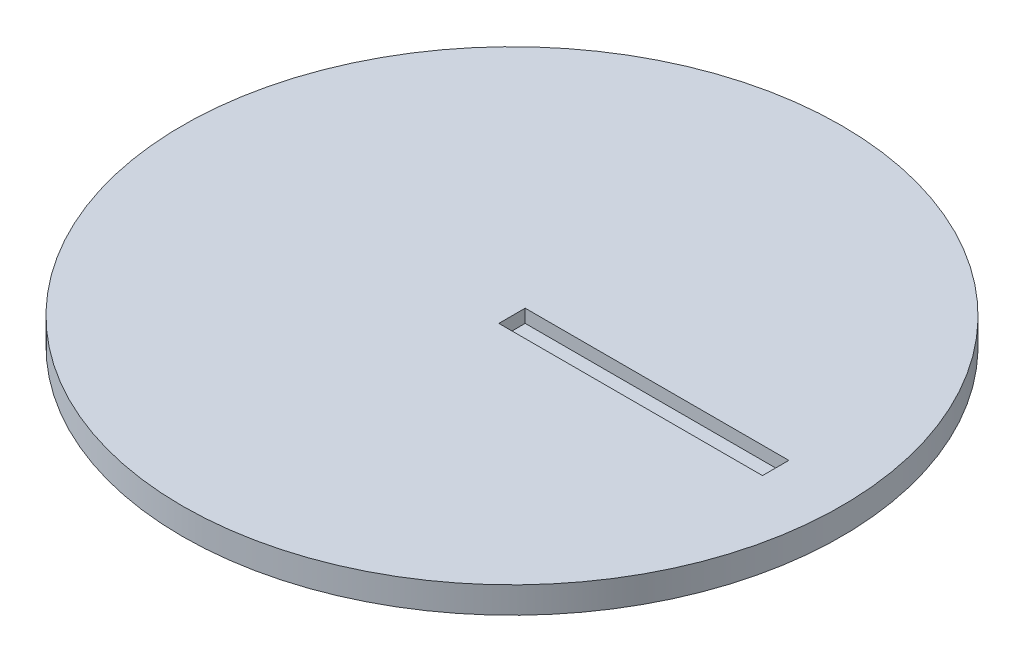
from build123d import *

# Parameters (mm, degrees)
SKETCH1_R                    = 25
BOSS_EXTRUDE1_DEPTH          = 2
SKETCH2_W                    = 20
SKETCH2_H                    = 2
CUT_EXTRUDE_THIN1_DEPTH      = 1
CUT_EXTRUDE_THIN1_DEPTH_BACK = 1


with BuildPart() as part:
    # Sketch1 → Boss-Extrude1 (new body)
    with BuildSketch(Plane(origin=(0, 0, 0), x_dir=(1, 0, 0), z_dir=(0, 1, 0))):
        Circle(SKETCH1_R)
    extrude(amount=BOSS_EXTRUDE1_DEPTH)

    # Sketch2 → Cut-Extrude-Thin1 (cut, two sides)
    with BuildSketch(Plane(origin=(0, 2, 0), x_dir=(1, 0, 0), z_dir=(0, 1, 0))) as cut_extrude_thin1_sk:
        with Locations((10, 0)):
            Rectangle(SKETCH2_W, SKETCH2_H)
    extrude(amount=CUT_EXTRUDE_THIN1_DEPTH, mode=Mode.SUBTRACT)
    extrude(cut_extrude_thin1_sk.sketch, amount=-CUT_EXTRUDE_THIN1_DEPTH_BACK, mode=Mode.SUBTRACT)


solid = part.part
